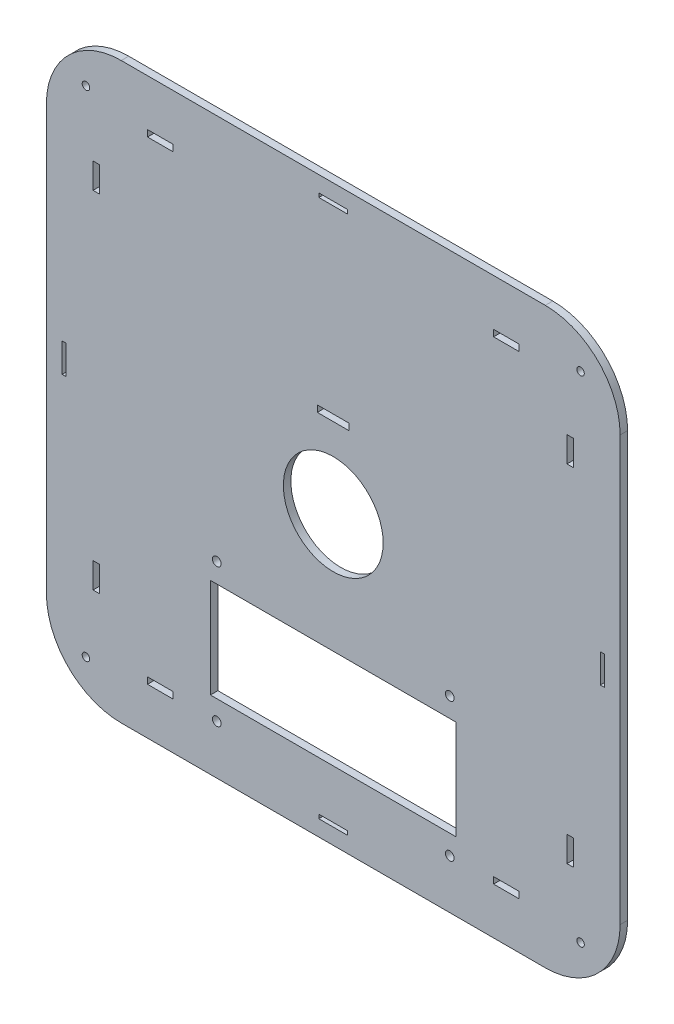
from build123d import *

# Parameters (mm, degrees)
CROQUIS1_R              = 1.5
CROQUIS1_R_2            = 1.75
CROQUIS1_R_3            = 20
CROQUIS1_W              = 98.5
CROQUIS1_H              = 39.8
CROQUIS1_W_2            = 10.2
CROQUIS1_H_2            = 2.6
CROQUIS1_W_3            = 2.6
CROQUIS1_H_3            = 10.2
CROQUIS1_W_4            = 1.6
CROQUIS1_H_4            = 11.6
CROQUIS1_W_5            = 12.8
CROQUIS1_H_5            = 2.62
CROQUIS1_W_6            = 11.6
CROQUIS1_H_6            = 1.6
SALIENTE_EXTRUIR1_DEPTH = 3


with BuildPart() as part:
    # Croquis1 → Saliente-Extruir1 (new body)
    with BuildSketch(Plane.XY):
        with BuildLine():
            Line((85, -115), (-85, -115))
            ThreePointArc((-85, -115), (-106.213203436, -106.213203436), (-115, -85))
            Line((-115, -85), (-115, 85))
            ThreePointArc((-115, 85), (-106.213203436, 106.213203436), (-85, 115))
            Line((-85, 115), (85, 115))
            ThreePointArc((85, 115), (106.213203436, 106.213203436), (115, 85))
            Line((115, 85), (115, -85))
            ThreePointArc((115, -85), (106.213203436, -106.213203436), (85, -115))
        make_face()
        with Locations((-99.142135624, 99.142135624)):
            Circle(CROQUIS1_R, mode=Mode.SUBTRACT)
        with Locations((-99.142135624, -99.142135624)):
            Circle(CROQUIS1_R, mode=Mode.SUBTRACT)
        with Locations((99.142135624, 99.142135624)):
            Circle(CROQUIS1_R, mode=Mode.SUBTRACT)
        with Locations((99.142135624, -99.142135624)):
            Circle(CROQUIS1_R, mode=Mode.SUBTRACT)
        with Locations((46.7, -39.75)):
            Circle(CROQUIS1_R_2, mode=Mode.SUBTRACT)
        with Locations((-46.7, -39.75)):
            Circle(CROQUIS1_R_2, mode=Mode.SUBTRACT)
        with Locations((46.7, -95.25)):
            Circle(CROQUIS1_R_2, mode=Mode.SUBTRACT)
        with Locations((-46.7, -95.25)):
            Circle(CROQUIS1_R_2, mode=Mode.SUBTRACT)
        Circle(CROQUIS1_R_3, mode=Mode.SUBTRACT)
        with Locations((0, -67.5)):
            Rectangle(CROQUIS1_W, CROQUIS1_H, mode=Mode.SUBTRACT)
        with Locations((69.375, 95)):
            Rectangle(CROQUIS1_W_2, CROQUIS1_H_2, mode=Mode.SUBTRACT)
        with Locations((69.375, -95)):
            Rectangle(CROQUIS1_W_2, CROQUIS1_H_2, mode=Mode.SUBTRACT)
        with Locations((-69.375, -95)):
            Rectangle(CROQUIS1_W_2, CROQUIS1_H_2, mode=Mode.SUBTRACT)
        with Locations((-69.375, 95)):
            Rectangle(CROQUIS1_W_2, CROQUIS1_H_2, mode=Mode.SUBTRACT)
        with Locations((-95, -69.375)):
            Rectangle(CROQUIS1_W_3, CROQUIS1_H_3, mode=Mode.SUBTRACT)
        with Locations((-95, 69.375)):
            Rectangle(CROQUIS1_W_3, CROQUIS1_H_3, mode=Mode.SUBTRACT)
        with Locations((95, -69.375)):
            Rectangle(CROQUIS1_W_3, CROQUIS1_H_3, mode=Mode.SUBTRACT)
        with Locations((95, 69.375)):
            Rectangle(CROQUIS1_W_3, CROQUIS1_H_3, mode=Mode.SUBTRACT)
        with Locations((107.843441478, 0)):
            Rectangle(CROQUIS1_W_4, CROQUIS1_H_4, mode=Mode.SUBTRACT)
        with Locations((0, 33.445401683)):
            Rectangle(CROQUIS1_W_5, CROQUIS1_H_5, mode=Mode.SUBTRACT)
        with Locations((-107.843441478, 0)):
            Rectangle(CROQUIS1_W_4, CROQUIS1_H_4, mode=Mode.SUBTRACT)
        with Locations((0, 107.843441478)):
            Rectangle(CROQUIS1_W_6, CROQUIS1_H_6, mode=Mode.SUBTRACT)
        with Locations((0, -107.843441478)):
            Rectangle(CROQUIS1_W_6, CROQUIS1_H_6, mode=Mode.SUBTRACT)
    extrude(amount=SALIENTE_EXTRUIR1_DEPTH)


solid = part.part
